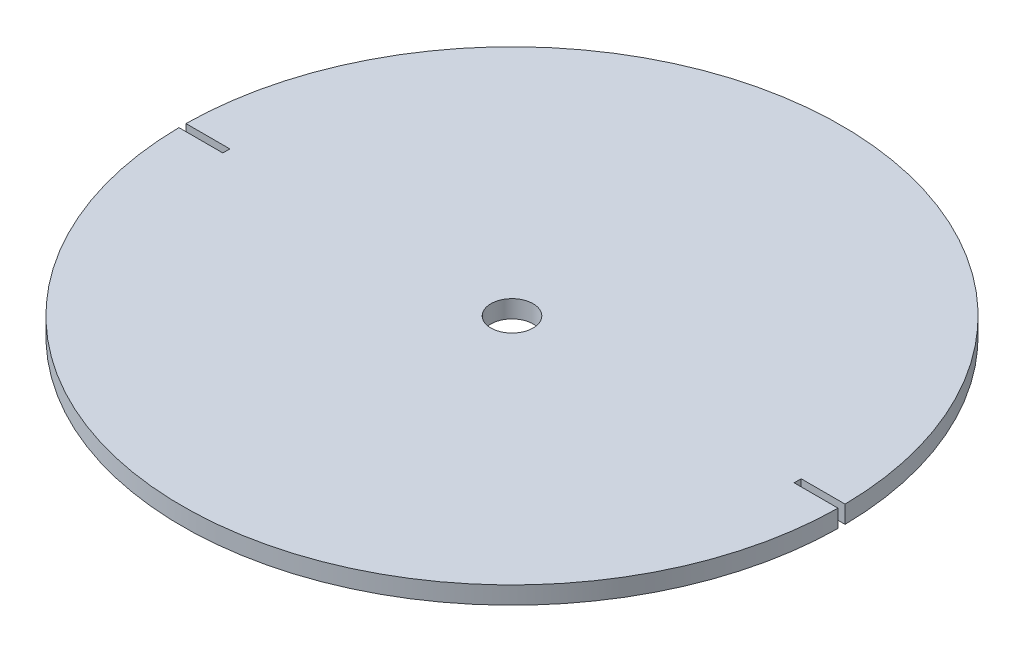
from build123d import *

# Parameters (mm, degrees)
SKETCH_3_R          = 37.5
EXTRUDE_1_DEPTH     = 2
CUT_EXTRUDE_5_DEPTH = 1.2
SKETCH_4_W          = 5
SKETCH_4_H          = 0.8
CUT_EXTRUDE_6_DEPTH = 54.070707551
SKETCH_5_R          = 2.4
CUT_EXTRUDE_7_DEPTH = 54.069200107


with BuildPart() as part:
    # 스케치3 → 보스-돌출1 (new body)
    with BuildSketch(Plane(origin=(0, 0, 0), x_dir=(1, 0, 0), z_dir=(0, 1, 0))):
        Circle(SKETCH_3_R)
    extrude(amount=EXTRUDE_1_DEPTH)

    # 스케치1 → 컷-돌출5 (cut)
    # profile 1 of 5: a face of its own
    with BuildSketch(Plane(origin=(0, 0, 0), x_dir=(1, 0, 0), z_dir=(0, 1, 0))):
        Polygon((-13.393920133, -32.335783638), (13.393920133, -32.335783638), (32.335783638, -13.393920133), (32.335783638, 13.393920133), (13.393920133, 32.335783638), (-13.393920133, 32.335783638), (-32.335783638, 13.393920133), (-32.335783638, -13.393920133), align=None)
        Polygon((31.335783638, -12.97970657), (12.97970657, -31.335783638), (-12.97970657, -31.335783638), (-31.335783638, -12.97970657), (-31.335783638, 12.97970657), (-12.97970657, 31.335783638), (12.97970657, 31.335783638), (31.335783638, 12.97970657), align=None, mode=Mode.SUBTRACT)
    # profile 2 of 5: a face of its own
    with BuildSketch(Plane(origin=(0, 0, 0), x_dir=(1, 0, 0), z_dir=(0, 1, 0))):
        Polygon((-11.671844687, -28.178325742), (11.671844687, -28.178325742), (28.178325742, -11.671844687), (28.178325742, 11.671844687), (11.671844687, 28.178325742), (-11.671844687, 28.178325742), (-28.178325742, 11.671844687), (-28.178325742, -11.671844687), align=None)
        Polygon((27.178325742, -11.257631125), (11.257631125, -27.178325742), (-11.257631125, -27.178325742), (-27.178325742, -11.257631125), (-27.178325742, 11.257631125), (-11.257631125, 27.178325742), (11.257631125, 27.178325742), (27.178325742, 11.257631125), align=None, mode=Mode.SUBTRACT)
    # profile 3 of 5: a face of its own
    with BuildSketch(Plane(origin=(0, 0, 0), x_dir=(1, 0, 0), z_dir=(0, 1, 0))):
        Polygon((-23.558928079, -9.758427525), (-9.758427525, -23.558928079), (9.758427525, -23.558928079), (23.558928079, -9.758427525), (23.558928079, 9.758427525), (9.758427525, 23.558928079), (-9.758427525, 23.558928079), (-23.558928079, 9.758427525), align=None)
        Polygon((9.344213963, -22.558928079), (-9.344213963, -22.558928079), (-22.558928079, -9.344213963), (-22.558928079, 9.344213963), (-9.344213963, 22.558928079), (9.344213963, 22.558928079), (22.558928079, 9.344213963), (22.558928079, -9.344213963), align=None, mode=Mode.SUBTRACT)
    # profile 4 of 5: a face of its own
    with BuildSketch(Plane(origin=(0, 0, 0), x_dir=(1, 0, 0), z_dir=(0, 1, 0))):
        Polygon((-7.749339505, -18.708560533), (7.749339505, -18.708560533), (18.708560533, -7.749339505), (18.708560533, 7.749339505), (7.749339505, 18.708560533), (-7.749339505, 18.708560533), (-18.708560533, 7.749339505), (-18.708560533, -7.749339505), align=None)
        Polygon((17.708560533, -7.335125943), (7.335125943, -17.708560533), (-7.335125943, -17.708560533), (-17.708560533, -7.335125943), (-17.708560533, 7.335125943), (-7.335125943, 17.708560533), (7.335125943, 17.708560533), (17.708560533, 7.335125943), align=None, mode=Mode.SUBTRACT)
    # profile 5 of 5: a face of its own
    with BuildSketch(Plane(origin=(0, 0, 0), x_dir=(1, 0, 0), z_dir=(0, 1, 0))):
        Polygon((5.931593202, 14.320132754), (-5.931593202, 14.320132754), (-14.320132754, 5.931593202), (-14.320132754, -5.931593202), (-5.931593202, -14.320132754), (5.931593202, -14.320132754), (14.320132754, -5.931593202), (14.320132754, 5.931593202), align=None)
        Polygon((-13.320132754, 5.517379639), (-5.517379639, 13.320132754), (5.517379639, 13.320132754), (13.320132754, 5.517379639), (13.320132754, -5.517379639), (5.517379639, -13.320132754), (-5.517379639, -13.320132754), (-13.320132754, -5.517379639), align=None, mode=Mode.SUBTRACT)
    extrude(amount=CUT_EXTRUDE_5_DEPTH, mode=Mode.SUBTRACT)

    # 스케치4 → 컷-돌출6 (cut, through all)
    with BuildSketch(Plane(origin=(0, 2, 0), x_dir=(1, 0, 0), z_dir=(0, 1, 0))):
        with Locations((-35, 0)):
            Rectangle(SKETCH_4_W, SKETCH_4_H)
        with Locations((35, 0)):
            Rectangle(SKETCH_4_W, SKETCH_4_H)
    extrude(amount=-CUT_EXTRUDE_6_DEPTH, mode=Mode.SUBTRACT)

    # 스케치5 → 컷-돌출7 (cut, through all)
    with BuildSketch(Plane(origin=(0, 2, 0), x_dir=(1, 0, 0), z_dir=(0, 1, 0))):
        Circle(SKETCH_5_R)
    extrude(amount=-CUT_EXTRUDE_7_DEPTH, mode=Mode.SUBTRACT)


solid = part.part
